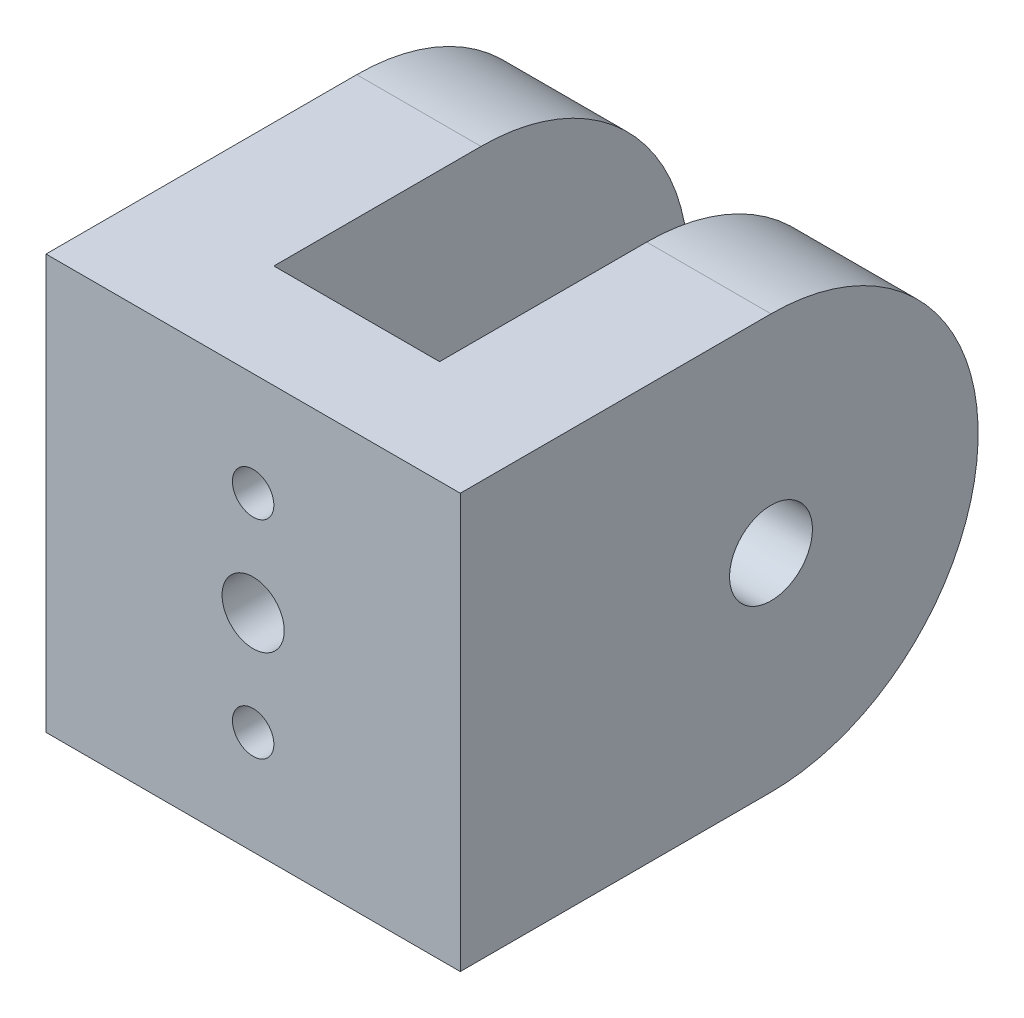
from build123d import *

# Parameters (mm, degrees)
SKETCH1_W           = 80
SKETCH1_H           = 80
BOSS_EXTRUDE1_DEPTH = 2
SKETCH2_W           = 80
SKETCH2_H           = 80
SKETCH2_W_2         = 78
SKETCH2_H_2         = 78
BOSS_EXTRUDE2_DEPTH = 15
FILLET1_R           = 20
FILLET2_R           = 10
FILLET3_R           = 20
FILLET4_R           = 10
SKETCH3_R           = 1
BOSS_EXTRUDE3_DEPTH = 6
SKETCH4_W           = 10
SKETCH4_H           = 10
BOSS_EXTRUDE4_DEPTH = 5
SKETCH5_W           = 6
SKETCH5_H           = 20
BOSS_EXTRUDE5_DEPTH = 20
CUT_EXTRUDE1_DEPTH  = 23
SKETCH7_R           = 2
CUT_EXTRUDE2_DEPTH  = 23
SKETCH8_R           = 3.5
CUT_EXTRUDE3_DEPTH  = 3
SKETCH9_R           = 1
CUT_EXTRUDE4_DEPTH  = 18
SKETCH10_R          = 1.5
CUT_EXTRUDE5_DEPTH  = 18
SKETCH11_R          = 69.283397128
CUT_EXTRUDE6_DEPTH  = 37


with BuildPart() as part:
    # Sketch1 → Boss-Extrude1 (new body)
    with BuildSketch(Plane.XY):
        with Locations((40, 40)):
            Rectangle(SKETCH1_W, SKETCH1_H)
    extrude(amount=BOSS_EXTRUDE1_DEPTH)

    # Sketch2 → Boss-Extrude2 (add)
    with BuildSketch(Plane.XY.offset(2)):
        with Locations((40, 40)):
            Rectangle(SKETCH2_W, SKETCH2_H)
        with Locations((40, 40)):
            Rectangle(SKETCH2_W_2, SKETCH2_H_2, mode=Mode.SUBTRACT)
    extrude(amount=BOSS_EXTRUDE2_DEPTH)

    # Fillet1
    fillet1_edges = [part.edges().sort_by_distance(p)[0] for p in [
        (1, 79, 9.5),
        (1, 1, 9.5),
        (79, 1, 9.5),
        (79, 79, 9.5),
    ]]
    fillet(fillet1_edges, radius=FILLET1_R)

    # Fillet2
    fillet2_edges = [part.edges().sort_by_distance(p)[0] for p in [
        (40, 1, 2),
        (79, 40, 2),
        (40, 79, 2),
        (1, 40, 2),
        (6.857864376, 73.142135624, 2),
        (73.142135624, 73.142135624, 2),
        (6.857864376, 6.857864376, 2),
        (73.142135624, 6.857864376, 2),
    ]]
    fillet(fillet2_edges, radius=FILLET2_R)

    # Fillet3
    fillet3_edges = [part.edges().sort_by_distance(p)[0] for p in [
        (0, 80, 8.5),
        (80, 80, 8.5),
        (80, 0, 8.5),
        (0, 0, 8.5),
    ]]
    fillet(fillet3_edges, radius=FILLET3_R)

    # Fillet4
    fillet4_edges = [part.edges().sort_by_distance(p)[0] for p in [
        (80, 40, 0),
        (0, 40, 0),
        (40, 80, 0),
        (40, 0, 0),
        (5.857864376, 5.857864376, 0),
        (5.857864376, 74.142135624, 0),
        (74.142135624, 74.142135624, 0),
        (74.142135624, 5.857864376, 0),
    ]]
    fillet(fillet4_edges, radius=FILLET4_R)

    # Sketch3 → Boss-Extrude3 (add)
    with BuildSketch(Plane.XY.offset(17)):
        with BuildLine():
            Line((72.292824946, 5.37212195), (70.635028843, 4.105439789))
            Line((70.635028843, 4.105439789), (70.635028843, 7.564971157))
            ThreePointArc((70.635028843, 7.564971157), (71.162236636, 8.837763364), (72.435028843, 9.364971157))
            Line((72.435028843, 9.364971157), (76.003973901, 9.364971157))
            Line((76.003973901, 9.364971157), (72.292824946, 5.37212195))
        make_face()
        with Locations((72.435028843, 7.564971157)):
            Circle(SKETCH3_R, mode=Mode.SUBTRACT)
        with BuildLine():
            Line((9.364971157, 4.105439789), (9.364971157, 7.564971157))
            ThreePointArc((9.364971157, 7.564971157), (8.837763364, 8.837763364), (7.564971157, 9.364971157))
            Line((7.564971157, 9.364971157), (3.996026099, 9.364971157))
            Line((3.996026099, 9.364971157), (7.707175054, 5.37212195))
            Line((7.707175054, 5.37212195), (9.364971157, 4.105439789))
        make_face()
        with Locations((7.564971157, 7.564971157)):
            Circle(SKETCH3_R, mode=Mode.SUBTRACT)
        with BuildLine():
            Line((70.635028843, 75.894560211), (70.635028843, 72.435028843))
            ThreePointArc((70.635028843, 72.435028843), (71.162236636, 71.162236636), (72.435028843, 70.635028843))
            Line((72.435028843, 70.635028843), (76.003973901, 70.635028843))
            Line((76.003973901, 70.635028843), (72.292824946, 74.62787805))
            Line((72.292824946, 74.62787805), (70.635028843, 75.894560211))
        make_face()
        with Locations((72.435028843, 72.435028843)):
            Circle(SKETCH3_R, mode=Mode.SUBTRACT)
        with BuildLine():
            Line((7.707175054, 74.62787805), (9.364971157, 75.894560211))
            Line((9.364971157, 75.894560211), (9.364971157, 72.435028843))
            ThreePointArc((9.364971157, 72.435028843), (8.837763364, 71.162236636), (7.564971157, 70.635028843))
            Line((7.564971157, 70.635028843), (3.996026099, 70.635028843))
            Line((3.996026099, 70.635028843), (7.707175054, 74.62787805))
        make_face()
        with Locations((7.564971157, 72.435028843)):
            Circle(SKETCH3_R, mode=Mode.SUBTRACT)
    extrude(amount=-BOSS_EXTRUDE3_DEPTH)

    # Sketch4 → Boss-Extrude4 (add)
    with BuildSketch(Plane(origin=(0, 0, 0), x_dir=(-1, 0, 0), z_dir=(0, 0, -1))):
        with Locations((-35, 35)):
            Rectangle(SKETCH4_W, SKETCH4_H)
        with Locations((-35, 45)):
            Rectangle(SKETCH4_W, SKETCH4_H)
        with Locations((-45, 45)):
            Rectangle(SKETCH4_W, SKETCH4_H)
        with Locations((-45, 35)):
            Rectangle(SKETCH4_W, SKETCH4_H)
    extrude(amount=BOSS_EXTRUDE4_DEPTH)

    # Sketch5 → Boss-Extrude5 (add)
    with BuildSketch(Plane(origin=(0, 0, -5), x_dir=(-1, 0, 0), z_dir=(0, 0, -1))):
        with Locations((-33, 40)):
            Rectangle(SKETCH5_W, SKETCH5_H)
        with Locations((-47, 40)):
            Rectangle(SKETCH5_W, SKETCH5_H)
    extrude(amount=BOSS_EXTRUDE5_DEPTH)

    # Sketch6 → Cut-Extrude1 (cut)
    with BuildSketch(Plane.ZY.offset(-30)):
        with BuildLine():
            Line((-15, 30), (-19.756708154, 21.186247086))
            Line((-19.756708154, 21.186247086), (-29.168380108, 27.64799201))
            Line((-29.168380108, 27.64799201), (-29.168380108, 53.846153493))
            Line((-29.168380108, 53.846153493), (-15, 50))
            ThreePointArc((-15, 50), (-25, 40), (-15, 30))
        make_face()
    extrude(amount=-CUT_EXTRUDE1_DEPTH, mode=Mode.SUBTRACT)

    # Sketch7 → Cut-Extrude2 (cut)
    with BuildSketch(Plane.ZY.offset(-30)):
        with Locations((-15, 40)):
            Circle(SKETCH7_R)
    extrude(amount=-CUT_EXTRUDE2_DEPTH, mode=Mode.SUBTRACT)

    # Sketch8 → Cut-Extrude3 (cut)
    with BuildSketch(Plane.ZY.offset(-30)):
        with Locations((-15, 40)):
            Circle(SKETCH8_R)
    extrude(amount=-CUT_EXTRUDE3_DEPTH, mode=Mode.SUBTRACT)

    # Sketch9 → Cut-Extrude4 (cut)
    with BuildSketch(Plane(origin=(0, 0, -5), x_dir=(-1, 0, 0), z_dir=(0, 0, -1))):
        with Locations((-40, 45)):
            Circle(SKETCH9_R)
        with Locations((-40, 35)):
            Circle(SKETCH9_R)
    extrude(amount=-CUT_EXTRUDE4_DEPTH, mode=Mode.SUBTRACT)

    # Sketch10 → Cut-Extrude5 (cut)
    with BuildSketch(Plane(origin=(0, 0, -5), x_dir=(-1, 0, 0), z_dir=(0, 0, -1))):
        with Locations((-40, 40)):
            Circle(SKETCH10_R)
    extrude(amount=-CUT_EXTRUDE5_DEPTH, mode=Mode.SUBTRACT)

    # Sketch11 → Cut-Extrude6 (cut)
    with BuildSketch(Plane(origin=(0, 0, 0), x_dir=(-1, 0, 0), z_dir=(0, 0, -1))):
        with Locations((-39.654791549, 38.656536987)):
            Circle(SKETCH11_R)
    extrude(amount=-CUT_EXTRUDE6_DEPTH, mode=Mode.SUBTRACT)


solid = part.part
